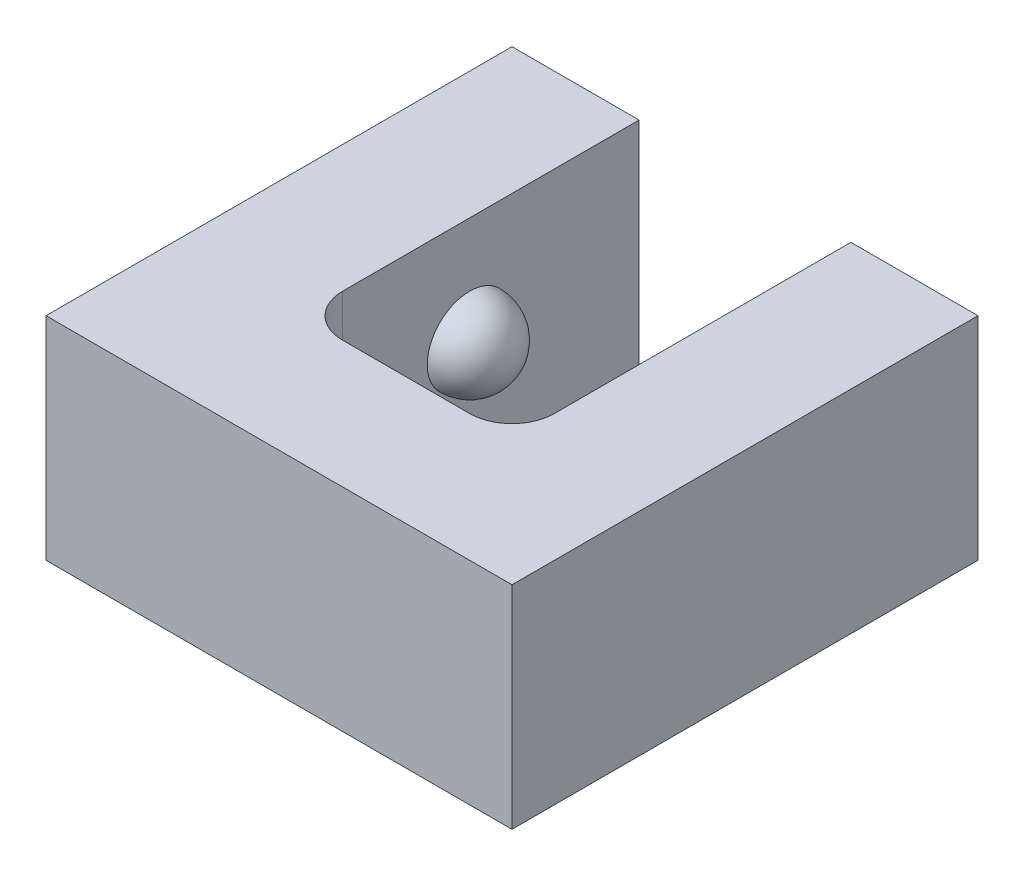
from build123d import *

# Parameters (mm, degrees)
BOSS_EXTRUDE1_DEPTH = 5
FILLET1_R           = 1


with BuildPart() as part:
    # Sketch1 → Boss-Extrude1 (new body)
    with BuildSketch(Plane(origin=(0, 0, 0), x_dir=(1, 0, 0), z_dir=(0, 1, 0))):
        Polygon((-5.5, 5.5), (-5.5, -5.5), (5.5, -5.5), (5.5, 5.5), (2.5, 5.5), (2.5, 2.5), (2.5, -2.5), (-2.5, -2.5), (-2.5, 2.5), (-2.5, 5.5), align=None)
    extrude(amount=BOSS_EXTRUDE1_DEPTH)

    # Sketch2 → Revolve1 (revolve)
    with BuildSketch(Plane(origin=(-2.5, 0, 0), x_dir=(0, 0, -1), z_dir=(1, 0, 0))):
        with BuildLine():
            Line((2.5, 2.5), (0.5, 2.5))
            ThreePointArc((0.5, 2.5), (1.5, 1.5), (2.5, 2.5))
        make_face()
    revolve1 = revolve(axis=Axis((-2.5, 2.5, -5.5), (0, 0, 1)))

    # Mirror1: Revolve1 across plane
    add(revolve1.mirror(Plane(origin=(0, 0, 0), x_dir=(0, 0, 1), z_dir=(1, 0, 0))))

    # Fillet1
    fillet1_edges = [part.edges().sort_by_distance(p)[0] for p in [
        (-2.5, 2.5, 2.5),
        (2.5, 2.5, 2.5),
    ]]
    fillet(fillet1_edges, radius=FILLET1_R)


solid = part.part
